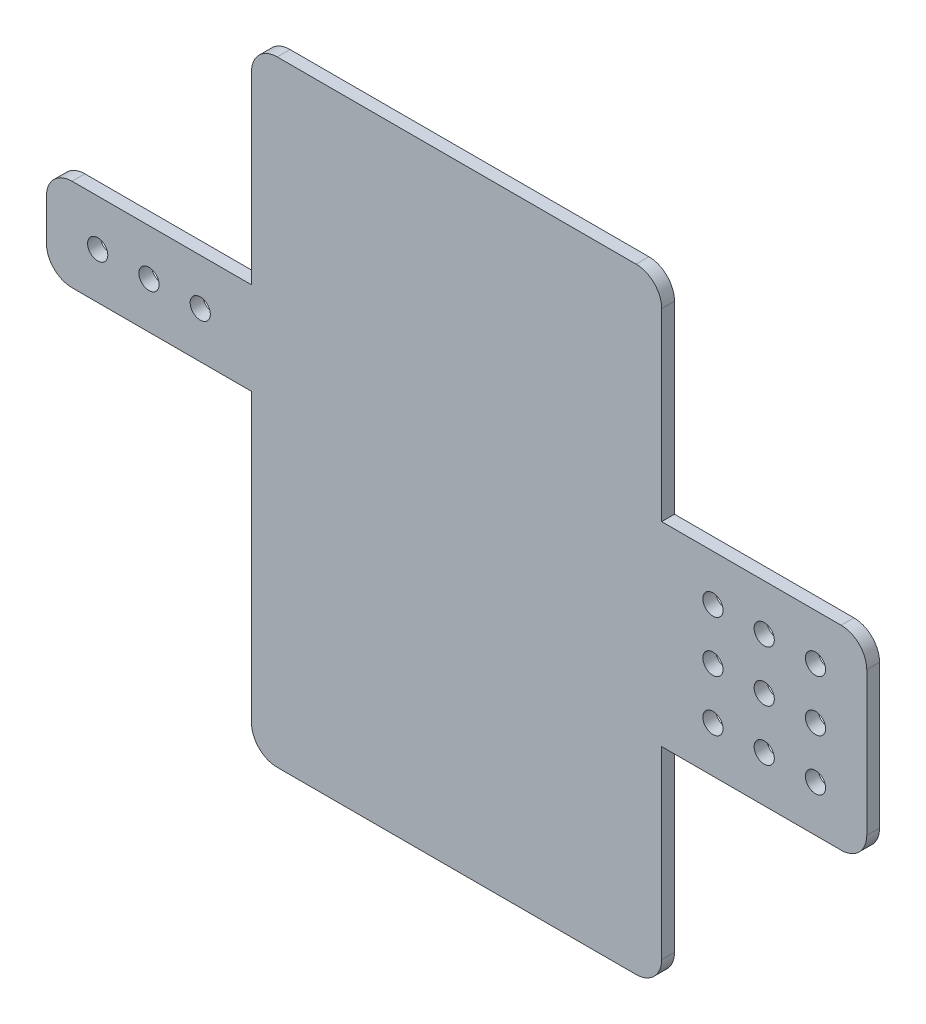
from build123d import *

# Parameters (mm, degrees)
BOSS_EXTRUDE1_DEPTH = 3.175
SKETCH2_R           = 2.5
CUT_EXTRUDE1_DEPTH  = 4.175


with BuildPart() as part:
    # Sketch1 → Boss-Extrude1 (new body)
    with BuildSketch(Plane.XY):
        with BuildLine():
            Line((-125.176151208, 25.103095989), (-36.276151208, 25.103095989))
            ThreePointArc((-36.276151208, 25.103095989), (-31.786023147, 23.24322405), (-29.926151208, 18.753095989))
            Line((-29.926151208, 18.753095989), (-29.926151208, -120.946904011))
            ThreePointArc((-29.926151208, -120.946904011), (-31.786023147, -125.437032071), (-36.276151208, -127.296904011))
            Line((-36.276151208, -127.296904011), (-125.176151208, -127.296904011))
            ThreePointArc((-125.176151208, -127.296904011), (-129.666279268, -125.437032071), (-131.526151208, -120.946904011))
            Line((-131.526151208, -120.946904011), (-131.526151208, 18.753095989))
            ThreePointArc((-131.526151208, 18.753095989), (-129.666279268, 23.24322405), (-125.176151208, 25.103095989))
        make_face()
        with BuildLine():
            Line((-131.526151208, -49.826904011), (-131.526151208, -26.966904011))
            Line((-131.526151208, -26.966904011), (-175.976151208, -26.966904011))
            ThreePointArc((-175.976151208, -26.966904011), (-180.466279268, -28.82677595), (-182.326151208, -33.316904011))
            Line((-182.326151208, -33.316904011), (-182.326151208, -43.476904011))
            ThreePointArc((-182.326151208, -43.476904011), (-180.466279268, -47.967032071), (-175.976151208, -49.826904011))
            Line((-175.976151208, -49.826904011), (-131.526151208, -49.826904011))
        make_face()
        with BuildLine():
            Line((14.523848792, -26.966904011), (-29.926151208, -26.966904011))
            Line((-29.926151208, -26.966904011), (-29.926151208, -75.226904011))
            Line((-29.926151208, -75.226904011), (14.523848792, -75.226904011))
            ThreePointArc((14.523848792, -75.226904011), (19.013976853, -73.367032071), (20.873848792, -68.876904011))
            Line((20.873848792, -68.876904011), (20.873848792, -33.316904011))
            ThreePointArc((20.873848792, -33.316904011), (19.013976853, -28.82677595), (14.523848792, -26.966904011))
        make_face()
    extrude(amount=BOSS_EXTRUDE1_DEPTH)

    # Sketch2 → Cut-Extrude1 (cut, through all)
    with BuildSketch(Plane.XY.offset(3.175)):
        with Locations((-169.626151208, -38.396904011)):
            Circle(SKETCH2_R)
        with Locations((8.173848792, -63.796904011)):
            Circle(SKETCH2_R)
        with Locations((-156.926151208, -38.396904011)):
            Circle(SKETCH2_R)
        with Locations((-144.226151208, -38.396904011)):
            Circle(SKETCH2_R)
        with Locations((-4.526151208, -63.796904011)):
            Circle(SKETCH2_R)
        with Locations((-17.226151208, -63.796904011)):
            Circle(SKETCH2_R)
        with Locations((-4.526151208, -51.096904011)):
            Circle(SKETCH2_R)
        with Locations((-17.226151208, -51.096904011)):
            Circle(SKETCH2_R)
        with Locations((-4.526151208, -38.396904011)):
            Circle(SKETCH2_R)
        with Locations((-17.226151208, -38.396904011)):
            Circle(SKETCH2_R)
        with Locations((8.173848792, -51.096904011)):
            Circle(SKETCH2_R)
        with Locations((8.173848792, -38.396904011)):
            Circle(SKETCH2_R)
    extrude(amount=-CUT_EXTRUDE1_DEPTH, mode=Mode.SUBTRACT)


solid = part.part
